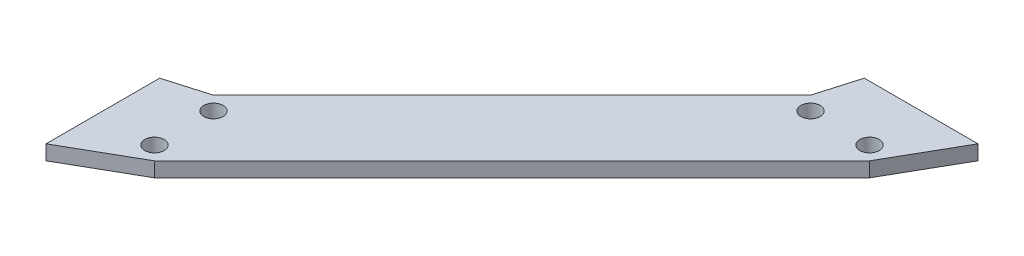
from build123d import *

# Parameters (mm, degrees)
SKETCH1_R           = 2.0828
BOSS_EXTRUDE1_DEPTH = 3.175


with BuildPart() as part:
    # Sketch1 → Boss-Extrude1 (new body)
    with BuildSketch(Plane(origin=(0, 0, 0), x_dir=(1, 0, 0), z_dir=(0, 1, 0))):
        Polygon((76.2, 0), (88.9, 0), (100.347298015, 0), (91.845524008, -14.851774008), (14.851774008, -91.845524008), (0, -100.347298015), (0, -88.9), (0, -76.2), (0, -75.865201985), (8.960725992, -73.254475992), (73.254475992, -8.960725992), (75.865201985, 0), align=None)
        with Locations((76.2, -11.90625)):
            Circle(SKETCH1_R, mode=Mode.SUBTRACT)
        with Locations((88.9, -11.90625)):
            Circle(SKETCH1_R, mode=Mode.SUBTRACT)
        with Locations((11.90625, -76.2)):
            Circle(SKETCH1_R, mode=Mode.SUBTRACT)
        with Locations((11.90625, -88.9)):
            Circle(SKETCH1_R, mode=Mode.SUBTRACT)
    extrude(amount=BOSS_EXTRUDE1_DEPTH)


solid = part.part
